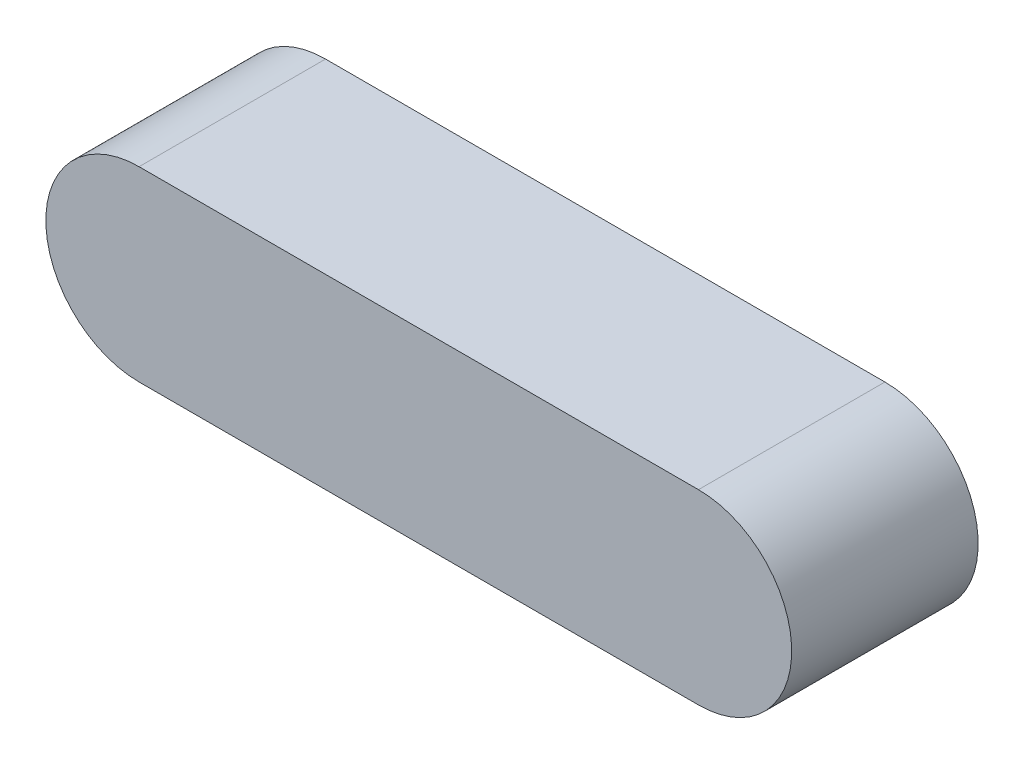
from build123d import *

# Parameters (mm, degrees)
SKETCH1_W         = 12.7
SKETCH1_H         = 3.175
EXTRUDE1_DEPTH    = 3.175
SKETCH2_OUTSIDE_W = 17.394
SKETCH2_OUTSIDE_H = 7.869
EXTRUDE2_DEPTH    = 4.175


with BuildPart() as part:
    # Sketch1 → Extrude1 (new body)
    with BuildSketch(Plane(origin=(0, 0, 0), x_dir=(1, 0, 0), z_dir=(0, 1, 0))):
        Rectangle(SKETCH1_W, SKETCH1_H)
    extrude(amount=-EXTRUDE1_DEPTH)

    # Sketch2 outside → Extrude2 (cut, through all)
    with BuildSketch(Plane(origin=(44.45, 6.35, 1.5875), x_dir=(-1, 0, 0), z_dir=(0, 0, -1))):
        with Locations((44.45, -7.9375)):
            Rectangle(SKETCH2_OUTSIDE_W, SKETCH2_OUTSIDE_H)
        with BuildLine():
            Line((39.6875, -6.35), (49.2125, -6.35))
            ThreePointArc((49.2125, -6.35), (50.8, -7.9375), (49.2125, -9.525))
            Line((49.2125, -9.525), (39.6875, -9.525))
            ThreePointArc((39.6875, -9.525), (38.1, -7.9375), (39.6875, -6.35))
        make_face(mode=Mode.SUBTRACT)
    extrude(amount=EXTRUDE2_DEPTH, mode=Mode.SUBTRACT)


solid = part.part
